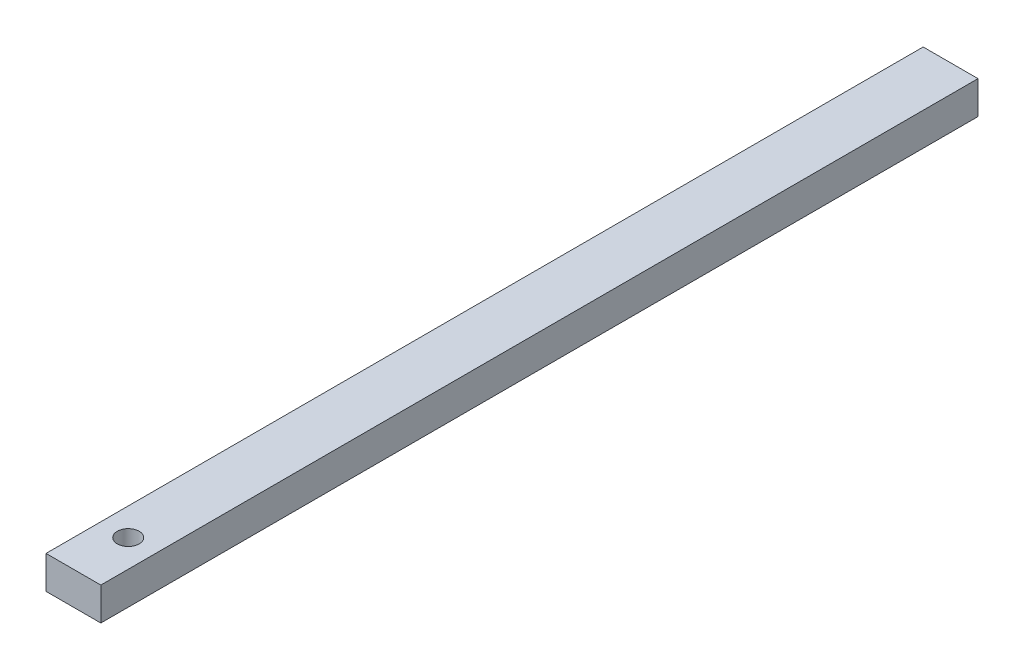
from build123d import *

# Parameters (mm, degrees)
SKETCH1_W           = 5
SKETCH1_H           = 3
BOSS_EXTRUDE1_DEPTH = 80
SKETCH2_R           = 1
CUT_EXTRUDE1_DEPTH  = 4


with BuildPart() as part:
    # Sketch1 → Boss-Extrude1 (new body)
    with BuildSketch(Plane.XY):
        Rectangle(SKETCH1_W, SKETCH1_H)
    extrude(amount=BOSS_EXTRUDE1_DEPTH)

    # Sketch2 → Cut-Extrude1 (cut, through all)
    with BuildSketch(Plane(origin=(0, 1.5, 0), x_dir=(1, 0, 0), z_dir=(0, 1, 0))):
        with Locations((0, -75)):
            Circle(SKETCH2_R)
    extrude(amount=-CUT_EXTRUDE1_DEPTH, mode=Mode.SUBTRACT)


solid = part.part
